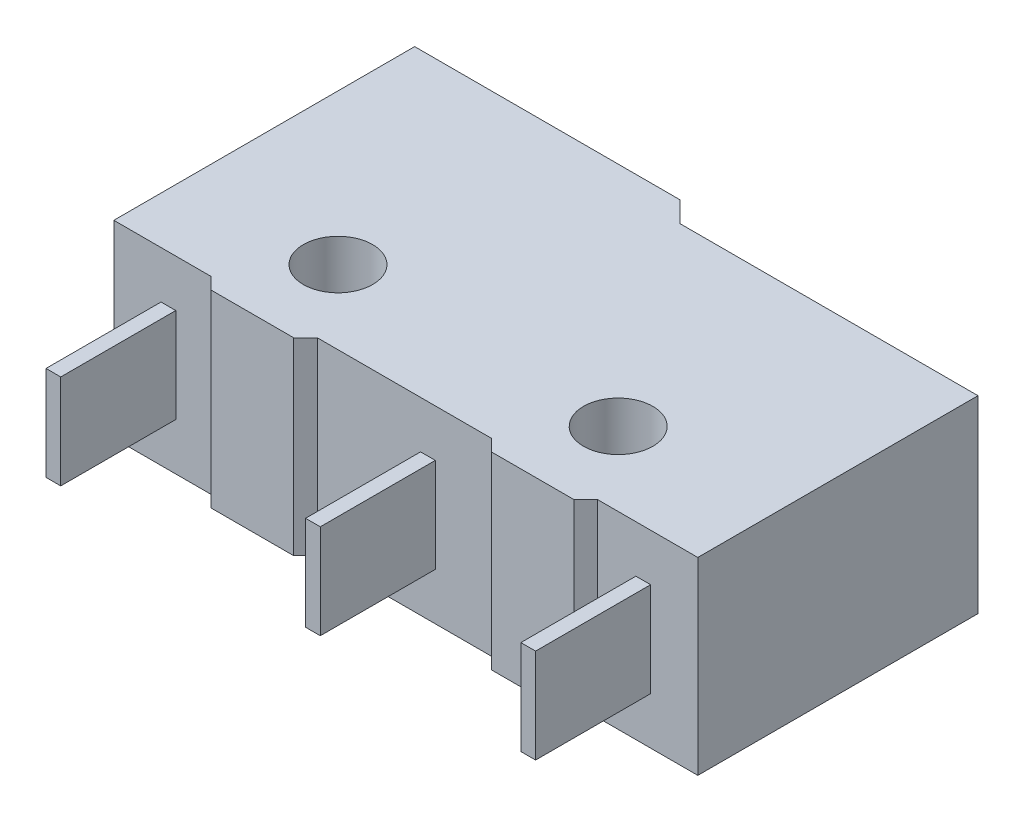
from build123d import *

# Parameters (mm, degrees)
SKETCH2_R                = 1.175
BOSS_EXTRUDE1_DEPTH      = 6.4
BOSS_EXTRUDE2_DEPTH      = 1.6
BOSS_EXTRUDE2_DEPTH_BACK = 1.6
SKETCH4_W                = 0.5
SKETCH4_H                = 3.9
BOSS_EXTRUDE3_DEPTH      = 1.6
BOSS_EXTRUDE3_DEPTH_BACK = 1.6


with BuildPart() as part:
    # Sketch2 → Boss-Extrude1 (new body)
    with BuildSketch(Plane(origin=(0, 0, 0), x_dir=(1, 0, 0), z_dir=(0, 1, 0))):
        Polygon((0, -2.9), (-1.4, -2.9), (-1.8, -2.5), (-5.1, -2.5), (-5.1, 7.7), (3.9, 7.7), (4.6, 7), (14.7, 7), (14.7, -2.5), (11.3, -2.5), (10.9, -2.9), (9.5, -2.9), (8.1, -2.9), (7.7, -2.5), (1.8, -2.5), (1.4, -2.9), align=None)
        Circle(SKETCH2_R, mode=Mode.SUBTRACT)
        with Locations((9.5, 0)):
            Circle(SKETCH2_R, mode=Mode.SUBTRACT)
    extrude(amount=BOSS_EXTRUDE1_DEPTH)

    # Sketch3 → Boss-Extrude2 (add, two sides)
    with BuildSketch(Plane(origin=(0, 3.2, 0), x_dir=(1, 0, 0), z_dir=(0, 1, 0))) as boss_extrude2_sk:
        with BuildLine():
            Line((3, 7.7), (1, 7.7))
            Line((1, 7.7), (1, 7.954))
            add(Edge.make_bspline(
                [(1, 7.954), (2, 9.1224), (3, 7.954)],
                knots=[0, 0, 0, 1, 1, 1], degree=2))
            Line((3, 7.954), (3, 7.7))
        make_face()
    extrude(amount=BOSS_EXTRUDE2_DEPTH)
    extrude(boss_extrude2_sk.sketch, amount=-BOSS_EXTRUDE2_DEPTH_BACK)

    # Sketch4 → Boss-Extrude3 (add, two sides)
    with BuildSketch(Plane(origin=(0, 3.2, 0), x_dir=(1, 0, 0), z_dir=(0, 1, 0))) as boss_extrude3_sk:
        with Locations((-3.25, -4.45)):
            Rectangle(SKETCH4_W, SKETCH4_H)
        with Locations((5.55, -4.45)):
            Rectangle(SKETCH4_W, SKETCH4_H)
        with Locations((12.85, -4.45)):
            Rectangle(SKETCH4_W, SKETCH4_H)
    extrude(amount=BOSS_EXTRUDE3_DEPTH)
    extrude(boss_extrude3_sk.sketch, amount=-BOSS_EXTRUDE3_DEPTH_BACK)


solid = part.part
